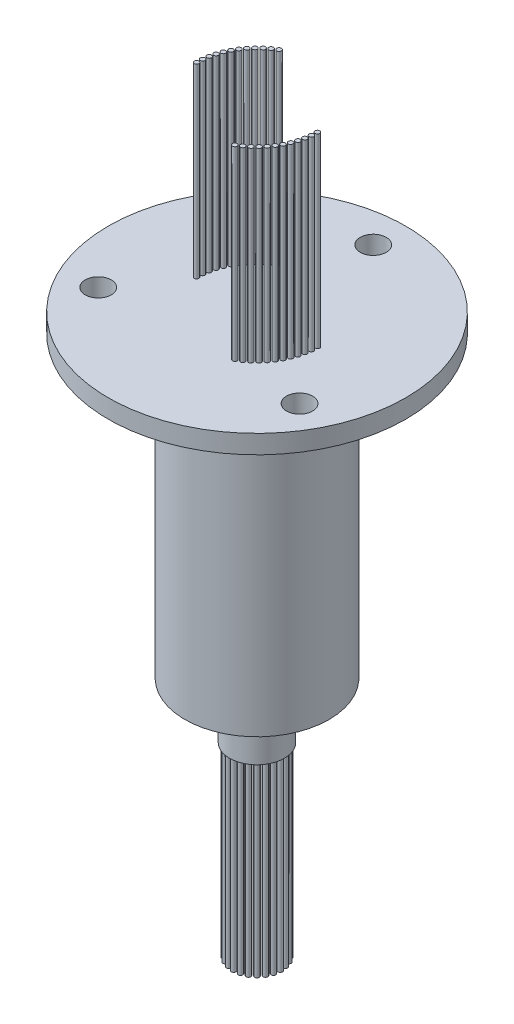
from build123d import *

# Parameters (mm, degrees)
SKETCH_2_R          = 1.4
CUT_EXTRUDE_1_DEPTH = 10
SKETCH_3_R          = 0.25
EXTRUDE_1_DEPTH     = 20
SKETCH_4_R          = 0.25
EXTRUDE_2_DEPTH     = 20


with BuildPart() as part:
    # 草图1 → 旋转1 (revolve)
    with BuildSketch(Plane.XY):
        Polygon((0, 40.1), (-16, 40.1), (-16, 38.1), (-7.75, 38.1), (-7.75, 6), (-2.95, 6), (-2.95, 0), (0, 0), align=None)
    revolve(axis=Axis((0, 0, 0), (0, 1, 0)))

    # 草图2 → 切除-拉伸1 (cut)
    with BuildSketch(Plane(origin=(0, 40.1, 0), x_dir=(1, 0, 0), z_dir=(0, 1, 0))):
        with Locations((0, 12.5)):
            Circle(SKETCH_2_R)
        with Locations((10.825317547, -6.25)):
            Circle(SKETCH_2_R)
        with Locations((-10.825317547, -6.25)):
            Circle(SKETCH_2_R)
    extrude(amount=-CUT_EXTRUDE_1_DEPTH, mode=Mode.SUBTRACT)

    # 草图3 → 凸台-拉伸1 (add)
    with BuildSketch(Plane(origin=(0, 40.1, 0), x_dir=(1, 0, 0), z_dir=(0, 1, 0))):
        with Locations((-6.5, 0)):
            Circle(SKETCH_3_R)
        with Locations((6.5, 0)):
            Circle(SKETCH_3_R)
        with Locations((-6.470567497, 0.617864281)):
            Circle(SKETCH_3_R)
        with Locations((6.470567497, -0.617864281)):
            Circle(SKETCH_3_R)
        with Locations((-6.382536532, 1.230133088)):
            Circle(SKETCH_3_R)
        with Locations((6.382536532, -1.230133088)):
            Circle(SKETCH_3_R)
        with Locations((-6.236704328, 1.831261619)):
            Circle(SKETCH_3_R)
        with Locations((6.236704328, -1.831261619)):
            Circle(SKETCH_3_R)
        with Locations((-6.034391565, 2.415805962)):
            Circle(SKETCH_3_R)
        with Locations((6.034391565, -2.415805962)):
            Circle(SKETCH_3_R)
        with Locations((-5.777430416, 2.978472391)):
            Circle(SKETCH_3_R)
        with Locations((5.777430416, -2.978472391)):
            Circle(SKETCH_3_R)
        with Locations((-5.468147963, 3.514165313)):
            Circle(SKETCH_3_R)
        with Locations((5.468147963, -3.514165313)):
            Circle(SKETCH_3_R)
        with Locations((-5.109345116, 4.01803341)):
            Circle(SKETCH_3_R)
        with Locations((5.109345116, -4.01803341)):
            Circle(SKETCH_3_R)
        with Locations((-4.704271248, 4.485513575)):
            Circle(SKETCH_3_R)
        with Locations((4.704271248, -4.485513575)):
            Circle(SKETCH_3_R)
        with Locations((-4.256594771, 4.912372233)):
            Circle(SKETCH_3_R)
        with Locations((4.256594771, -4.912372233)):
            Circle(SKETCH_3_R)
        with Locations((-3.770369912, 5.294743688)):
            Circle(SKETCH_3_R)
        with Locations((3.770369912, -5.294743688)):
            Circle(SKETCH_3_R)
        with Locations((-3.25, 5.629165125)):
            Circle(SKETCH_3_R)
        with Locations((3.25, -5.629165125)):
            Circle(SKETCH_3_R)
    extrude(amount=EXTRUDE_1_DEPTH)

    # 草图4 → 凸台-拉伸2 (add)
    with BuildSketch(Plane.XZ):
        with Locations((0, -2.5)):
            Circle(SKETCH_4_R)
        with Locations((-0.647047613, -2.414814566)):
            Circle(SKETCH_4_R)
        with Locations((-1.25, -2.165063509)):
            Circle(SKETCH_4_R)
        with Locations((-1.767766953, -1.767766953)):
            Circle(SKETCH_4_R)
        with Locations((-2.165063509, -1.25)):
            Circle(SKETCH_4_R)
        with Locations((-2.414814566, -0.647047613)):
            Circle(SKETCH_4_R)
        with Locations((-2.5, 0)):
            Circle(SKETCH_4_R)
        with Locations((-2.414814566, 0.647047613)):
            Circle(SKETCH_4_R)
        with Locations((-2.165063509, 1.25)):
            Circle(SKETCH_4_R)
        with Locations((-1.767766953, 1.767766953)):
            Circle(SKETCH_4_R)
        with Locations((-1.25, 2.165063509)):
            Circle(SKETCH_4_R)
        with Locations((-0.647047613, 2.414814566)):
            Circle(SKETCH_4_R)
        with Locations((0, 2.5)):
            Circle(SKETCH_4_R)
        with Locations((0.647047613, 2.414814566)):
            Circle(SKETCH_4_R)
        with Locations((1.25, 2.165063509)):
            Circle(SKETCH_4_R)
        with Locations((1.767766953, 1.767766953)):
            Circle(SKETCH_4_R)
        with Locations((2.165063509, 1.25)):
            Circle(SKETCH_4_R)
        with Locations((2.414814566, 0.647047613)):
            Circle(SKETCH_4_R)
        with Locations((2.5, 0)):
            Circle(SKETCH_4_R)
        with Locations((2.414814566, -0.647047613)):
            Circle(SKETCH_4_R)
        with Locations((2.165063509, -1.25)):
            Circle(SKETCH_4_R)
        with Locations((1.767766953, -1.767766953)):
            Circle(SKETCH_4_R)
        with Locations((1.25, -2.165063509)):
            Circle(SKETCH_4_R)
        with Locations((0.647047613, -2.414814566)):
            Circle(SKETCH_4_R)
    extrude(amount=EXTRUDE_2_DEPTH)


solid = part.part
